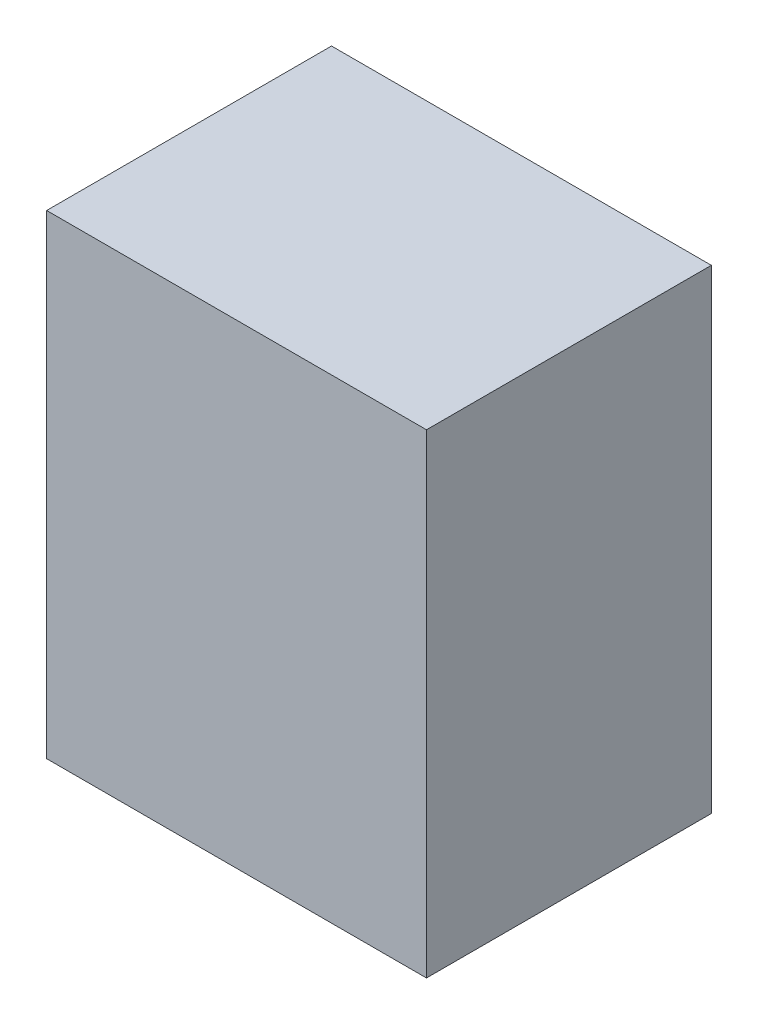
from build123d import *

# Parameters (mm, degrees)
ESBO_O1_W                = 40
ESBO_O1_H                = 50
RESSALTO_EXTRUS_O1_DEPTH = 30


with BuildPart() as part:
    # Esboço1 → Ressalto-extrusão1 (new body)
    with BuildSketch(Plane.XY):
        Rectangle(ESBO_O1_W, ESBO_O1_H)
    extrude(amount=RESSALTO_EXTRUS_O1_DEPTH)


solid = part.part
